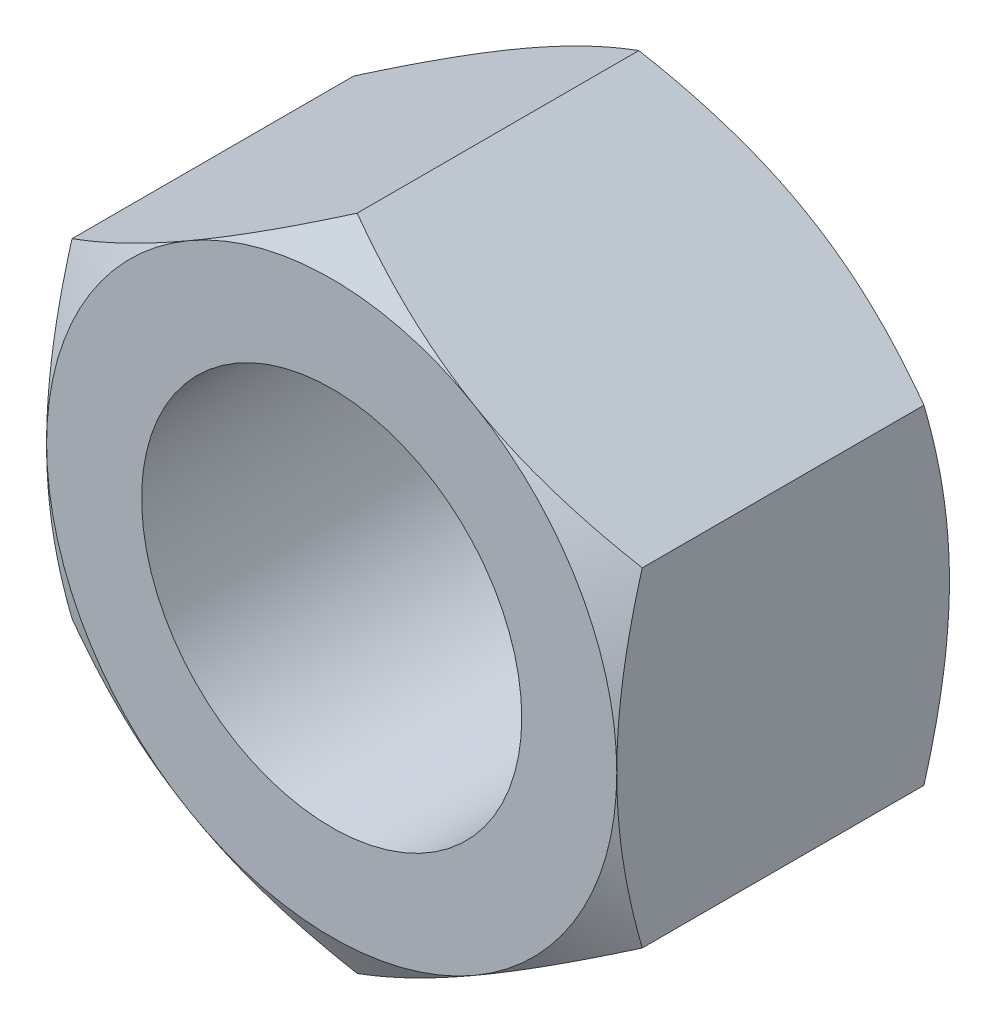
from build123d import *

# Parameters (mm, degrees)
SKETCH1_R               = 6.35
EXTRUDE1_DEPTH          = 5.55625
SKETCH7_OUTSIDE_W       = 115.268
SKETCH7_OUTSIDE_H       = 118.216
SKETCH7_OUTSIDE_R       = 9.525
EXTRUDE2_DEPTH          = 25.4
EXTRUDE2_DRAFT          = -60
MIRROR1_COPY_1_SKETCH_W = 115.268
MIRROR1_COPY_1_SKETCH_H = 118.216
MIRROR1_COPY_1_SKETCH_R = 9.525
MIRROR1_COPY_1_DEPTH    = 25.4
MIRROR1_COPY_1_DRAFT    = -60


with BuildPart() as part:
    # Sketch1 → Extrude1 (new, symmetric)
    with BuildSketch(Plane.XY):
        Polygon((-9.525, 5.499261314), (-9.525, -5.499261314), (0, -10.998522628), (9.525, -5.499261314), (9.525, 5.499261314), (0, 10.998522628), align=None)
        Circle(SKETCH1_R, mode=Mode.SUBTRACT)
    extrude(amount=EXTRUDE1_DEPTH, both=True)


with BuildPart() as extrude2_tool:
    # Sketch7 outside → Extrude2 (with draft: the straight prism first)
    with BuildSketch(Plane.XY.offset(5.55625)):
        Rectangle(SKETCH7_OUTSIDE_W, SKETCH7_OUTSIDE_H)
        Circle(SKETCH7_OUTSIDE_R, mode=Mode.SUBTRACT)
    extrude(amount=-EXTRUDE2_DEPTH)
    # Extrude2: the draft: its side faces are tilted about the plane it starts from
    extrude2_sides = [extrude2_tool.faces().sort_by_distance(p)[0] for p in [
        (0, -59.108, -7.14375),
        (57.634, 0, -7.14375),
        (0, 59.108, -7.14375),
        (-57.634, 0, -7.14375),
        (-9.525, 0, -7.14375),
    ]]
    draft(extrude2_sides, Plane.XY.offset(5.55625), EXTRUDE2_DRAFT)


with BuildPart() as part_1:
    add(part.part)

    # Extrude2: cut by extrude2_tool
    add(extrude2_tool.part, mode=Mode.SUBTRACT)


with BuildPart() as mirror1_copy_1_tool:
    # Mirror1 copy 1 sketch → Mirror1 copy 1 (with draft: the straight prism first)
    with BuildSketch(Plane(origin=(0, 0, -5.55625), x_dir=(1, 0, 0), z_dir=(0, 0, -1))):
        Rectangle(MIRROR1_COPY_1_SKETCH_W, MIRROR1_COPY_1_SKETCH_H)
        Circle(MIRROR1_COPY_1_SKETCH_R, mode=Mode.SUBTRACT)
    extrude(amount=-MIRROR1_COPY_1_DEPTH)
    # Mirror1 copy 1: the draft: its side faces are tilted about the plane it starts from
    mirror1_copy_1_sides = [mirror1_copy_1_tool.faces().sort_by_distance(p)[0] for p in [
        (0, -59.108, 7.14375),
        (57.634, 0, 7.14375),
        (0, 59.108, 7.14375),
        (-57.634, 0, 7.14375),
        (-9.525, 0, 7.14375),
    ]]
    draft(mirror1_copy_1_sides, Plane(origin=(0, 0, -5.55625), x_dir=(1, 0, 0), z_dir=(0, 0, -1)), MIRROR1_COPY_1_DRAFT)


with BuildPart() as part_2:
    add(part_1.part)

    # Mirror1 copy 1: cut by mirror1_copy_1_tool
    add(mirror1_copy_1_tool.part, mode=Mode.SUBTRACT)


solid = part_2.part
